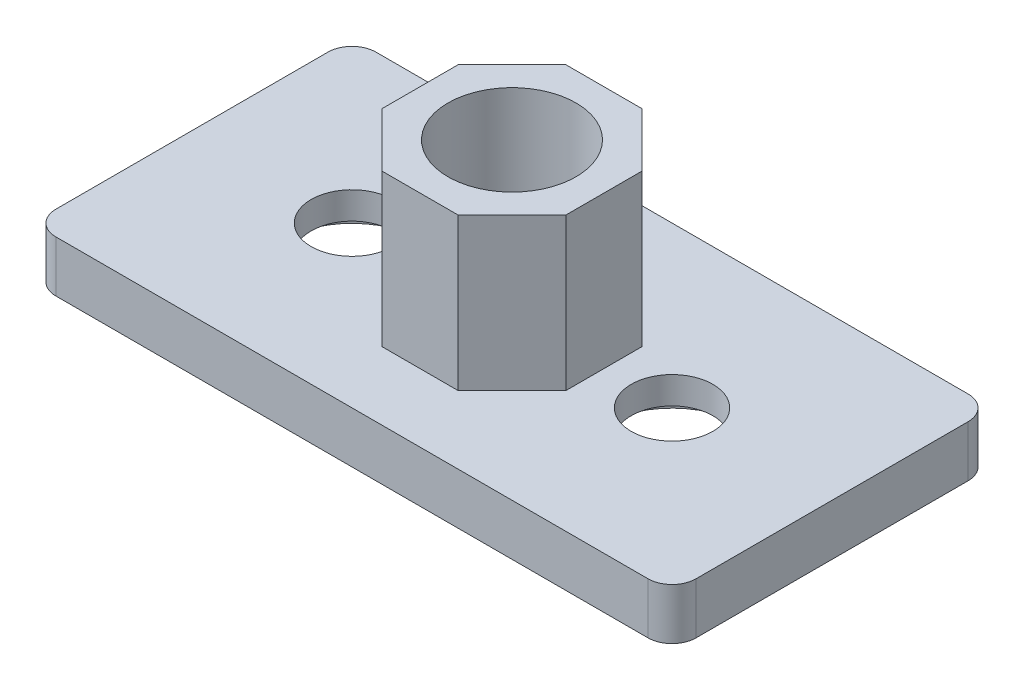
from build123d import *

# Parameters (mm, degrees)
SKETCH1_W           = 40
SKETCH1_H           = 3.2
BOSS_EXTRUDE1_DEPTH = 20
SKETCH3_R           = 2.55
CUT_EXTRUDE2_DEPTH  = 4.2
SKETCH5_R           = 4.5
CUT_EXTRUDE4_DEPTH  = 1.5
BOSS_EXTRUDE2_DEPTH = 9.5
SKETCH7_R           = 4
CUT_EXTRUDE5_DEPTH  = 13.7
FILLET1_R           = 1.5


with BuildPart() as part:
    # Sketch1 → Boss-Extrude1 (new body)
    with BuildSketch(Plane.XY):
        Rectangle(SKETCH1_W, SKETCH1_H)
    extrude(amount=BOSS_EXTRUDE1_DEPTH)

    # Sketch3 → Cut-Extrude2 (cut, through all)
    with BuildSketch(Plane(origin=(0, 1.6, 0), x_dir=(1, 0, 0), z_dir=(0, 1, 0))):
        with Locations((-10, -10)):
            Circle(SKETCH3_R)
        with Locations((10, -10)):
            Circle(SKETCH3_R)
    extrude(amount=-CUT_EXTRUDE2_DEPTH, mode=Mode.SUBTRACT)

    # Sketch5 → Cut-Extrude4 (cut)
    with BuildSketch(Plane.XZ.offset(1.6)):
        with Locations((10, 10)):
            Circle(SKETCH5_R)
        with Locations((-10, 10)):
            Circle(SKETCH5_R)
    extrude(amount=-CUT_EXTRUDE4_DEPTH, mode=Mode.SUBTRACT)

    # Sketch6 → Boss-Extrude2 (add)
    with BuildSketch(Plane(origin=(0, 1.6, 0), x_dir=(1, 0, 0), z_dir=(0, 1, 0))):
        Polygon((-2.381727984, -4.25), (-5.75, -7.618272016), (-5.75, -12.381727984), (-2.381727984, -15.75), (2.381727984, -15.75), (5.75, -12.381727984), (5.75, -7.618272016), (2.381727984, -4.25), align=None)
    extrude(amount=BOSS_EXTRUDE2_DEPTH)

    # Sketch7 → Cut-Extrude5 (cut, through all)
    with BuildSketch(Plane(origin=(0, 11.1, 0), x_dir=(1, 0, 0), z_dir=(0, 1, 0))):
        with Locations((0, -10)):
            Circle(SKETCH7_R)
    extrude(amount=-CUT_EXTRUDE5_DEPTH, mode=Mode.SUBTRACT)

    # Fillet1
    fillet1_edges = [part.edges().sort_by_distance(p)[0] for p in [
        (20, 0, 20),
        (-20, 0, 20),
        (20, 0, 0),
        (-20, 0, 0),
    ]]
    fillet(fillet1_edges, radius=FILLET1_R)


solid = part.part
